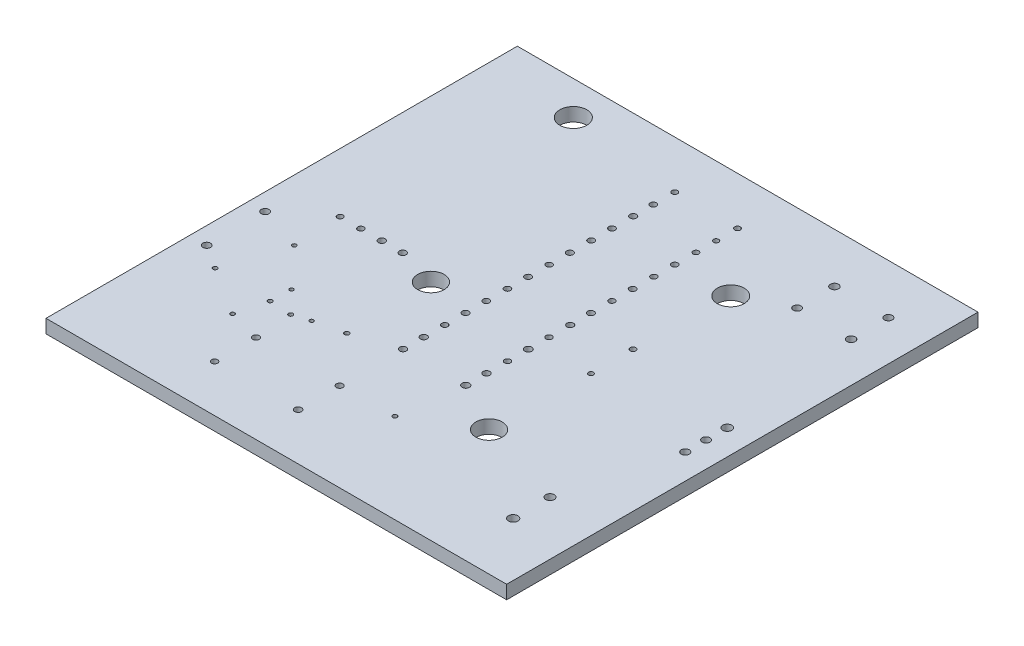
from build123d import *

# Parameters (mm, degrees)
SKETCH1_W           = 54.61
SKETCH1_H           = 55.88
BOSS_EXTRUDE1_DEPTH = 1.6
SKETCH2_R           = 1.59938652
SKETCH2_R_2         = 1.593077756
SKETCH2_R_3         = 0.452574799
SKETCH2_R_4         = 0.480028064
SKETCH2_R_5         = 0.465129332
SKETCH2_R_6         = 0.486649453
SKETCH2_R_7         = 1.565869332
SKETCH2_R_8         = 0.397895911
SKETCH2_R_9         = 0.397882454
SKETCH2_R_10        = 0.356595037
SKETCH2_R_11        = 0.333594003
SKETCH2_R_12        = 0.239542347
SKETCH2_R_13        = 0.226201547
SKETCH2_R_14        = 0.233275918
SKETCH2_R_15        = 0.256166525
SKETCH2_R_16        = 0.255392926
SKETCH2_R_17        = 0.248136055
SKETCH2_R_18        = 0.447662922
SKETCH2_R_19        = 0.452252407
SKETCH2_R_20        = 0.239942714
SKETCH2_R_21        = 0.391464076
SKETCH2_R_22        = 0.360331554
SKETCH2_R_23        = 0.404490663
SKETCH2_R_24        = 0.384788584
SKETCH2_R_25        = 0.257107561
SKETCH2_R_26        = 0.273253907
SKETCH2_R_27        = 0.39651489
SKETCH2_R_28        = 0.393350562
SKETCH2_R_29        = 0.355618877
SKETCH2_R_30        = 0.377526949
SKETCH2_R_31        = 0.377766955
SKETCH2_R_32        = 0.36325523
SKETCH2_R_33        = 0.378551554
SKETCH2_R_34        = 0.355329697
SKETCH2_R_35        = 0.382997324
SKETCH2_R_36        = 0.369709734
SKETCH2_R_37        = 0.37124433
SKETCH2_R_38        = 0.385916857
SKETCH2_R_39        = 0.363938308
SKETCH2_R_40        = 0.333537697
SKETCH2_R_41        = 0.310028392
SKETCH2_R_42        = 0.333886041
SKETCH2_R_43        = 0.330283809
SKETCH2_R_44        = 0.364374395
SKETCH2_R_45        = 0.353792472
SKETCH2_R_46        = 0.372885559
SKETCH2_R_47        = 0.348600153
SKETCH2_R_48        = 0.384803628
SKETCH2_R_49        = 0.387591086
SKETCH2_R_50        = 0.354490901
SKETCH2_R_51        = 0.415876944
SKETCH2_R_52        = 0.351498041
SKETCH2_R_53        = 0.392374017
SKETCH2_R_54        = 0.434288257
SKETCH2_R_55        = 0.292605843
SKETCH2_R_56        = 0.335537626
SKETCH2_R_57        = 1.564224328
SKETCH2_R_58        = 0.508580285
SKETCH2_R_59        = 0.555593041
SKETCH2_R_60        = 0.530092741
SKETCH2_R_61        = 0.459629548
SKETCH2_R_62        = 0.465333024
CUT_EXTRUDE1_DEPTH  = 2.6


with BuildPart() as part:
    # Sketch1 → Boss-Extrude1 (new body)
    with BuildSketch(Plane(origin=(0, 0, 0), x_dir=(1, 0, 0), z_dir=(0, 1, 0))):
        Rectangle(SKETCH1_W, SKETCH1_H)
    extrude(amount=BOSS_EXTRUDE1_DEPTH)

    # Sketch2 → Cut-Extrude1 (cut, through all)
    with BuildSketch(Plane(origin=(0, 1.6, 0), x_dir=(1, 0, 0), z_dir=(0, 1, 0))):
        with Locations((-16.664297308, 23.932043145)):
            Circle(SKETCH2_R)
        with Locations((10.980265243, 14.950869261)):
            Circle(SKETCH2_R_2)
        with Locations((16.166703819, 17.6326375)):
            Circle(SKETCH2_R_3)
        with Locations((16.166703819, 22.060085065)):
            Circle(SKETCH2_R_4)
        with Locations((22.567528012, 22.060085065)):
            Circle(SKETCH2_R_5)
        with Locations((22.567528012, 17.6326375)):
            Circle(SKETCH2_R_6)
        with Locations((-8.213065376, -1.3990828)):
            Circle(SKETCH2_R_7)
        with Locations((-12.880776497, -0.068306864)):
            Circle(SKETCH2_R_8)
        with Locations((-15.367822181, -0.068306864)):
            Circle(SKETCH2_R_9)
        with Locations((-17.854706203, -0.068306864)):
            Circle(SKETCH2_R_10)
        with Locations((-20.312369623, -0.068306864)):
            Circle(SKETCH2_R_11)
        with Locations((-20.075921844, -5.738541726)):
            Circle(SKETCH2_R_12)
        with Locations((-15.704587313, -10.428115561)):
            Circle(SKETCH2_R_13)
        with Locations((-11.307135458, -12.45851306)):
            Circle(SKETCH2_R_14)
        with Locations((-13.190051269, -13.04767065)):
            Circle(SKETCH2_R_15)
        with Locations((-15.784379921, -12.883809097)):
            Circle(SKETCH2_R_16)
        with Locations((-22.431122431, -12.765558111)):
            Circle(SKETCH2_R_17)
        with Locations((-25.275605658, -10.917044443)):
            Circle(SKETCH2_R_18)
        with Locations((-25.275605658, -3.991987316)):
            Circle(SKETCH2_R_19)
        with Locations((-16.705936806, -16.421463043)):
            Circle(SKETCH2_R_20)
        with Locations((-12.880776497, -17.459342868)):
            Circle(SKETCH2_R_21)
        with Locations((-12.880776497, -22.375845154)):
            Circle(SKETCH2_R_22)
        with Locations((-2.983360407, -22.375845154)):
            Circle(SKETCH2_R_23)
        with Locations((-2.983360407, -17.459342868)):
            Circle(SKETCH2_R_24)
        with Locations((3.427815902, -17.319364157)):
            Circle(SKETCH2_R_25)
        with Locations((-7.932777582, -11.644816009)):
            Circle(SKETCH2_R_26)
        with Locations((-2.983360407, -9.935549628)):
            Circle(SKETCH2_R_27)
        with Locations((-2.983360407, -7.480563575)):
            Circle(SKETCH2_R_28)
        with Locations((-2.983360407, -4.987813874)):
            Circle(SKETCH2_R_29)
        with Locations((-2.983360407, -2.521390191)):
            Circle(SKETCH2_R_30)
        with Locations((-2.983360407, -0.068306864)):
            Circle(SKETCH2_R_31)
        with Locations((-2.983360407, 2.444706456)):
            Circle(SKETCH2_R_32)
        with Locations((-2.983360407, 4.893099371)):
            Circle(SKETCH2_R_33)
        with Locations((-2.983360407, 7.385639552)):
            Circle(SKETCH2_R_34)
        with Locations((-2.983360407, 9.849195982)):
            Circle(SKETCH2_R_35)
        with Locations((-2.983360407, 12.363056337)):
            Circle(SKETCH2_R_36)
        with Locations((-2.983360407, 14.833883975)):
            Circle(SKETCH2_R_37)
        with Locations((-2.983360407, 17.348014362)):
            Circle(SKETCH2_R_38)
        with Locations((-2.983360407, 19.737222803)):
            Circle(SKETCH2_R_39)
        with Locations((-2.983360407, 22.277194941)):
            Circle(SKETCH2_R_40)
        with Locations((4.456862321, 19.737222803)):
            Circle(SKETCH2_R_41)
        with Locations((4.456862321, 22.277194941)):
            Circle(SKETCH2_R_42)
        with Locations((4.456862321, 17.348014362)):
            Circle(SKETCH2_R_43)
        with Locations((4.456862321, 14.833883975)):
            Circle(SKETCH2_R_44)
        with Locations((4.456862321, 12.363056337)):
            Circle(SKETCH2_R_45)
        with Locations((4.456862321, 9.849195982)):
            Circle(SKETCH2_R_46)
        with Locations((4.456862321, 7.385639552)):
            Circle(SKETCH2_R_47)
        with Locations((4.456862321, 4.893099371)):
            Circle(SKETCH2_R_48)
        with Locations((4.456862321, 2.444706456)):
            Circle(SKETCH2_R_49)
        with Locations((4.456862321, -0.068306864)):
            Circle(SKETCH2_R_50)
        with Locations((4.456862321, -2.521390191)):
            Circle(SKETCH2_R_51)
        with Locations((4.456862321, -4.987813874)):
            Circle(SKETCH2_R_52)
        with Locations((4.456862321, -7.480563575)):
            Circle(SKETCH2_R_53)
        with Locations((4.456862321, -9.935549628)):
            Circle(SKETCH2_R_54)
        with Locations((10.669719496, -1.304797587)):
            Circle(SKETCH2_R_55)
        with Locations((10.669719496, 3.682313247)):
            Circle(SKETCH2_R_56)
        with Locations((10.377113652, -13.101088656)):
            Circle(SKETCH2_R_57)
        with Locations((20.92912061, -16.421463043)):
            Circle(SKETCH2_R_58)
        with Locations((20.92912061, -20.789810067)):
            Circle(SKETCH2_R_59)
        with Locations((24.309641026, 1.206553039)):
            Circle(SKETCH2_R_60)
        with Locations((24.309641026, -1.304797587)):
            Circle(SKETCH2_R_61)
        with Locations((24.309641026, -3.770776983)):
            Circle(SKETCH2_R_62)
    extrude(amount=-CUT_EXTRUDE1_DEPTH, mode=Mode.SUBTRACT)


solid = part.part
